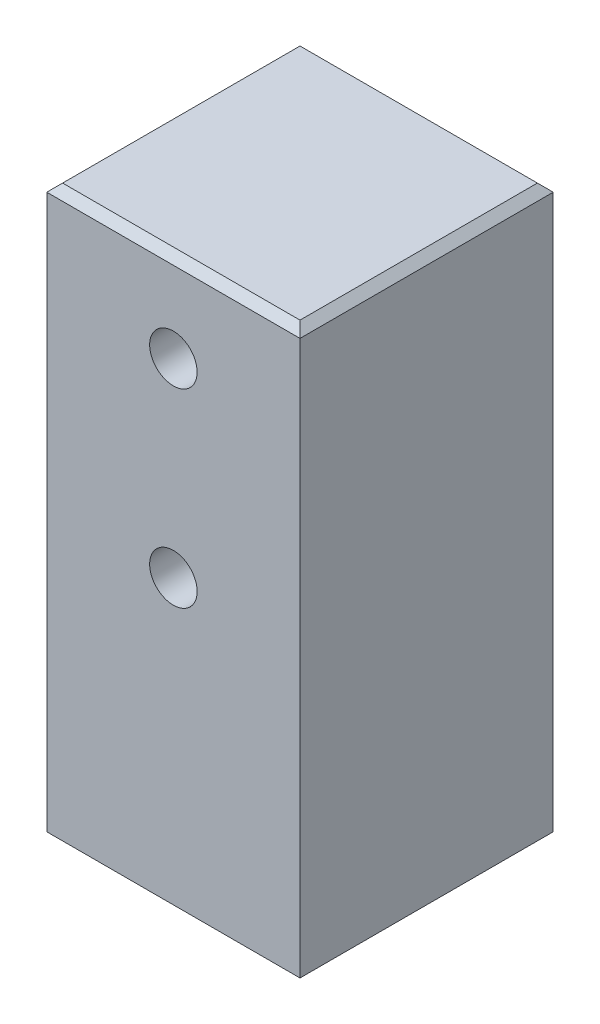
from build123d import *

# Parameters (mm, degrees)
SKETCH1_W               = 25.4
SKETCH1_H               = 25.4
BOSS_EXTRUDE1_DEPTH     = 28.575
SKETCH2_R               = 3.175
CUT_EXTRUDE1_DEPTH      = 16.51
SKETCH5_R               = 2.38125
CUT_EXTRUDE3_DEPTH      = 13.7
CUT_EXTRUDE3_DEPTH_BACK = 13.7
CHAMFER1_SIZE           = 0.79375
SKETCH6_R               = 1.35255
CUT_EXTRUDE4_DEPTH      = 6.35


with BuildPart() as part:
    # Sketch1 → Boss-Extrude1 (new body, symmetric)
    with BuildSketch(Plane(origin=(0, 0, 0), x_dir=(1, 0, 0), z_dir=(0, 1, 0))):
        Rectangle(SKETCH1_W, SKETCH1_H)
    extrude(amount=BOSS_EXTRUDE1_DEPTH, both=True)

    # Sketch2 → Cut-Extrude1 (cut)
    with BuildSketch(Plane(origin=(0, -28.575, 0), x_dir=(-1, 0, 0), z_dir=(0, -1, 0))):
        Circle(SKETCH2_R)
    extrude(amount=-CUT_EXTRUDE1_DEPTH, mode=Mode.SUBTRACT)

    # Sketch5 → Cut-Extrude3 (cut, two sides)
    with BuildSketch(Plane.XY) as cut_extrude3_sk:
        with Locations((0, 0.635)):
            Circle(SKETCH5_R)
        with Locations((0, 19.685)):
            Circle(SKETCH5_R)
    extrude(amount=CUT_EXTRUDE3_DEPTH, mode=Mode.SUBTRACT)
    extrude(cut_extrude3_sk.sketch, amount=-CUT_EXTRUDE3_DEPTH_BACK, mode=Mode.SUBTRACT)

    # Chamfer1
    chamfer1_edges = [part.edges().sort_by_distance(p)[0] for p in [
        (-12.7, 28.575, 0),
        (0, 28.575, 12.7),
        (12.7, 28.575, 0),
        (0, -28.575, 12.7),
        (-12.7, -28.575, 0),
        (0, -28.575, -12.7),
        (12.7, -28.575, 0),
        (0, 28.575, -12.7),
    ]]
    chamfer(chamfer1_edges, length=CHAMFER1_SIZE)

    # Sketch6 → Cut-Extrude4 (cut)
    with BuildSketch(Plane(origin=(0, -28.575, 0), x_dir=(-1, 0, 0), z_dir=(0, -1, 0))):
        with Locations((-5.656854249, 5.656854249)):
            Circle(SKETCH6_R)
        with Locations((5.656854249, 5.656854249)):
            Circle(SKETCH6_R)
        with Locations((5.656854249, -5.656854249)):
            Circle(SKETCH6_R)
        with Locations((-5.656854249, -5.656854249)):
            Circle(SKETCH6_R)
    extrude(amount=-CUT_EXTRUDE4_DEPTH, mode=Mode.SUBTRACT)


solid = part.part
